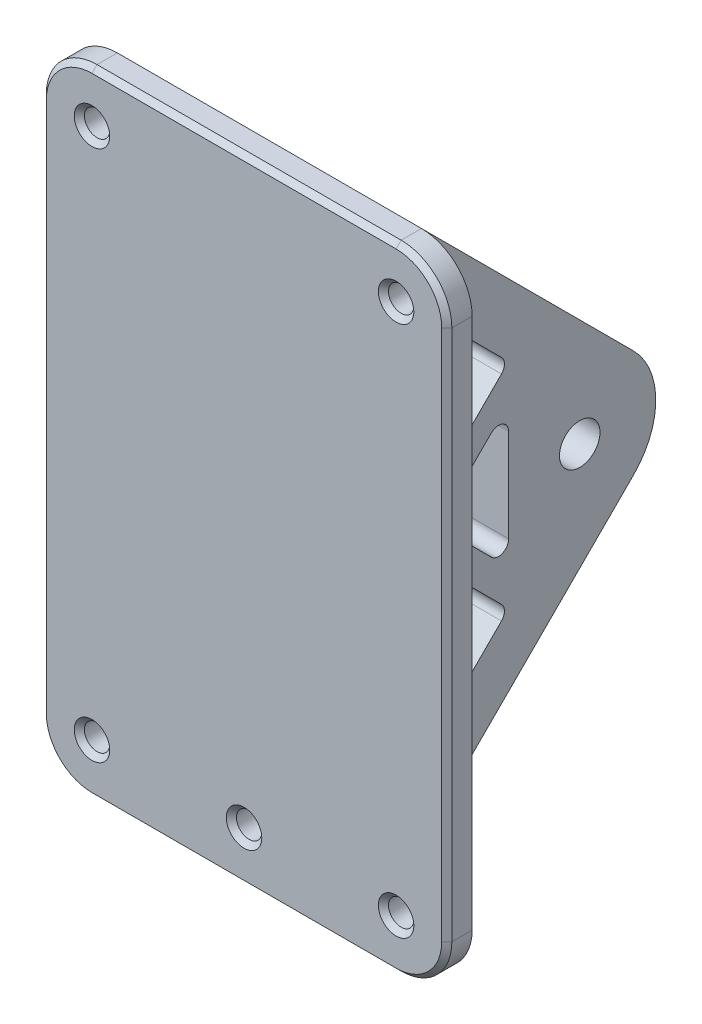
from build123d import *

# Parameters (mm, degrees)
ESBO_O1_R                = 4
RESSALTO_EXTRUS_O2_DEPTH = 10
ESBO_O2_W                = 80
ESBO_O2_H                = 124.892668507
ESBO_O2_R                = 2.5
RESSALTO_EXTRUS_O3_DEPTH = 5
FILETE5_R                = 2
FILETE6_R                = 5
FILETE7_R                = 10
CHANFRO1_SIZE            = 1


with BuildPart() as part:
    # Esboço1 → Ressalto-extrusão2 (new body)
    with BuildSketch(Plane(origin=(10, 0, 0), x_dir=(0, 0, -1), z_dir=(1, 0, 0))):
        with BuildLine():
            Line((51.839732536, -73.052935971), (0, -124.892668507))
            Line((0, -124.892668507), (0, 0))
            Line((0, 0), (51.839732536, -51.839732536))
            ThreePointArc((51.839732536, -51.839732536), (56.233130818, -62.446334254), (51.839732536, -73.052935971))
        make_face()
        with Locations((41.233130818, -62.446334254)):
            Circle(ESBO_O1_R, mode=Mode.SUBTRACT)
        Polygon((10, -24.142135624), (10, -58.553710058), (27.205787217, -41.347922841), align=None, mode=Mode.SUBTRACT)
        Polygon((10, -100.750532883), (27.205787217, -83.544745666), (10, -66.338958449), align=None, mode=Mode.SUBTRACT)
        Polygon((27.205787217, -48.418990653), (27.205787217, -76.473677854), (13.178443616, -62.446334254), align=None, mode=Mode.SUBTRACT)
    extrude(amount=RESSALTO_EXTRUS_O2_DEPTH)


with BuildPart() as body_2:
    # Espelhar2: mirrored copy
    add(part.part.mirror(Plane(origin=(0, 0, 0), x_dir=(0, 0, 1), z_dir=(1, 0, 0))))


with BuildPart() as part_1:
    add(part.part)

    add(body_2.part)  # Ressalto-extrusão3 merges body 2
    # Esboço2 → Ressalto-extrusão3 (add)
    with BuildSketch(Plane.XY):
        with Locations((0, -62.446334254)):
            Rectangle(ESBO_O2_W, ESBO_O2_H)
        with Locations((-30, -10)):
            Circle(ESBO_O2_R, mode=Mode.SUBTRACT)
        with Locations((30, -10)):
            Circle(ESBO_O2_R, mode=Mode.SUBTRACT)
        with Locations((-30, -114.892668507)):
            Circle(ESBO_O2_R, mode=Mode.SUBTRACT)
        with Locations((30, -114.892668507)):
            Circle(ESBO_O2_R, mode=Mode.SUBTRACT)
        with Locations((0, -114.892668507)):
            Circle(ESBO_O2_R, mode=Mode.SUBTRACT)
    extrude(amount=RESSALTO_EXTRUS_O3_DEPTH)

    # Filete5
    filete5_edges = [part_1.edges().sort_by_distance(p)[0] for p in [
        (15, -100.750532883, -10),
        (15, -83.544745666, -27.205787217),
        (15, -66.338958449, -10),
        (15, -24.142135624, -10),
        (15, -58.553710058, -10),
        (15, -41.347922841, -27.205787217),
        (15, -76.473677854, -27.205787217),
        (15, -48.418990653, -27.205787217),
        (15, -62.446334254, -13.178443616),
    ]]
    fillet(filete5_edges, radius=FILETE5_R)

    # Filete6
    filete6_edges = [part_1.edges().sort_by_distance(p)[0] for p in [
        (10, -62.446334254, 0),
        (20, -62.446334254, 0),
        (-10, -62.446334254, 0),
        (-20, -62.446334254, 0),
    ]]
    fillet(filete6_edges, radius=FILETE6_R)

    # Filete7
    filete7_edges = [part_1.edges().sort_by_distance(p)[0] for p in [
        (-40, 0, 2.5),
        (-40, -124.892668507, 2.5),
        (40, -124.892668507, 2.5),
        (40, 0, 2.5),
    ]]
    fillet(filete7_edges, radius=FILETE7_R)

    # Chanfro1
    chanfro1_edges = [part_1.edges().sort_by_distance(p)[0] for p in [
        (0, -124.892668507, 5),
        (-40, -62.446334254, 5),
        (40, -62.446334254, 5),
        (0, 0, 5),
        (37.071067812, -2.928932188, 5),
        (-37.071067812, -2.928932188, 5),
        (37.071067812, -121.963736319, 5),
        (-37.071067812, -121.963736319, 5),
        (-32.5, -10, 5),
        (27.5, -10, 5),
        (-32.5, -114.892668507, 5),
        (27.5, -114.892668507, 5),
        (-2.5, -114.892668507, 5),
    ]]
    chamfer(chanfro1_edges, length=CHANFRO1_SIZE)


solid = part_1.part
